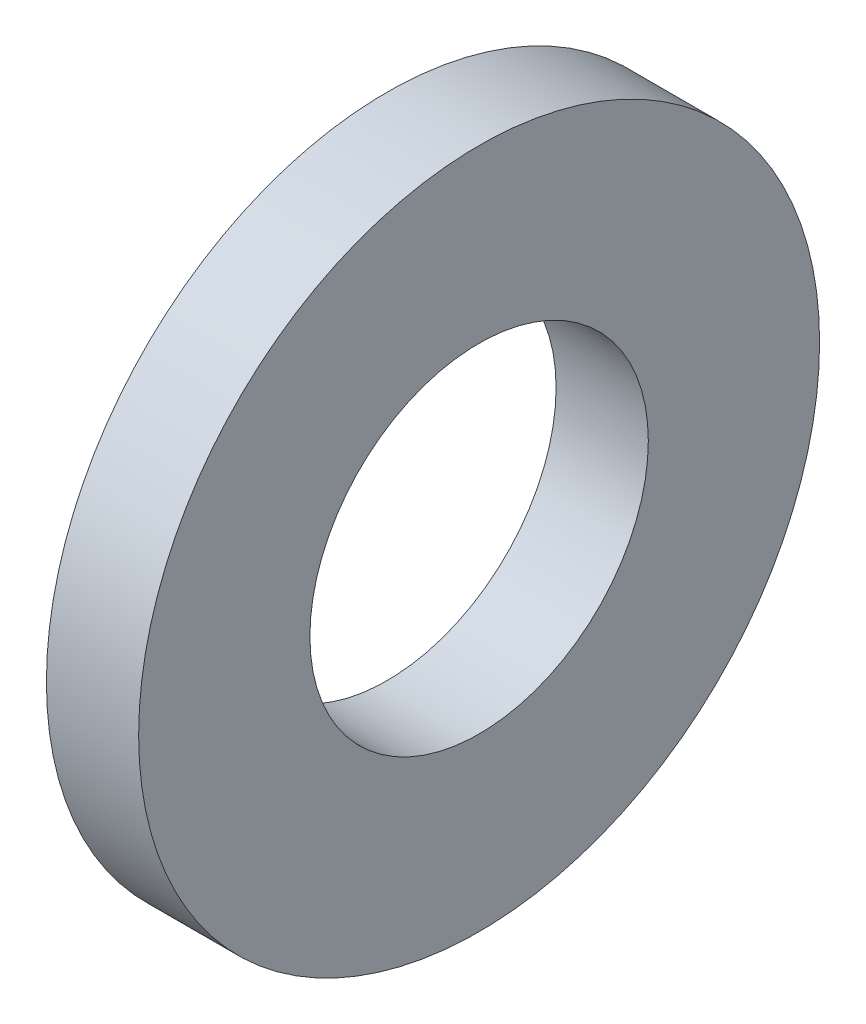
from build123d import *

# Parameters (mm, degrees)
SKETCH1_R           = 10.5029
SKETCH1_R_2         = 5.2197
BOSS_EXTRUDE1_DEPTH = 2.8448


with BuildPart() as part:
    # Sketch1 → Boss-Extrude1 (new body)
    with BuildSketch(Plane(origin=(0, 0, 0), x_dir=(0, 0, -1), z_dir=(1, 0, 0))):
        Circle(SKETCH1_R)
        Circle(SKETCH1_R_2, mode=Mode.SUBTRACT)
    extrude(amount=BOSS_EXTRUDE1_DEPTH)


solid = part.part
